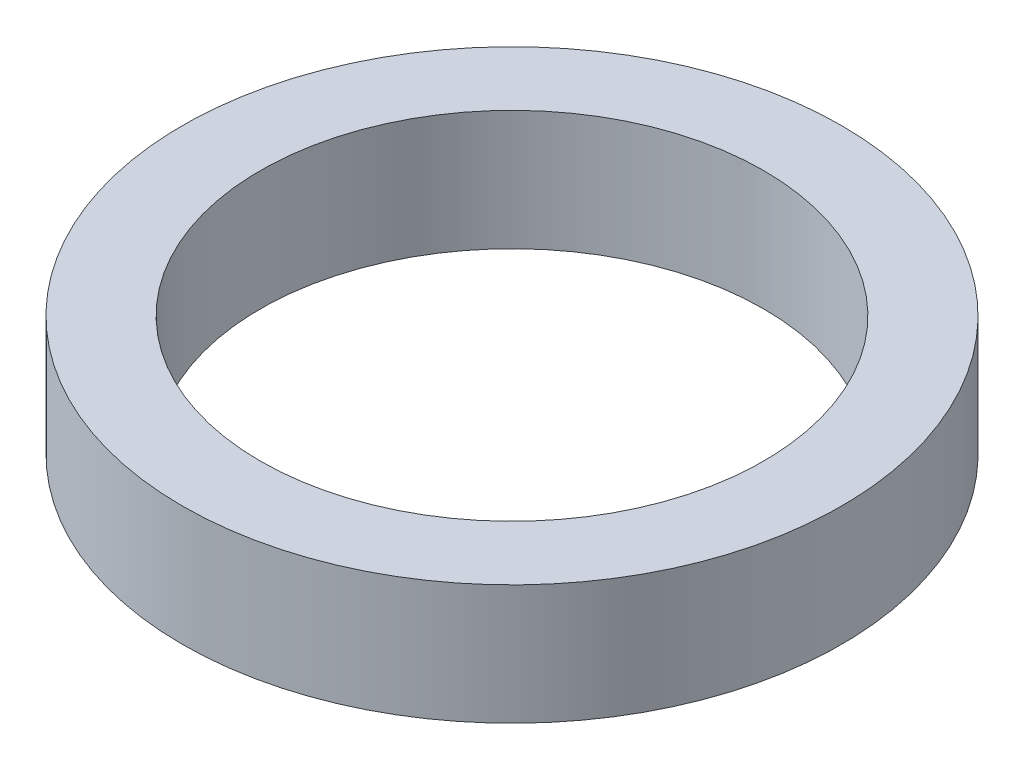
from build123d import *

# Parameters (mm, degrees)
SKETCH1_R           = 5.5
SKETCH1_R_2         = 4.2
BOSS_EXTRUDE1_DEPTH = 2


with BuildPart() as part:
    # Sketch1 → Boss-Extrude1 (new body)
    with BuildSketch(Plane(origin=(0, 0, 0), x_dir=(1, 0, 0), z_dir=(0, 1, 0))):
        with Locations(Location((0, 0, 0), (0, 0, 270))):  # turned: the seam where the file's is
            Circle(SKETCH1_R)
        with Locations(Location((0, 0, 0), (0, 0, 270))):  # turned: the seam where the file's is
            Circle(SKETCH1_R_2, mode=Mode.SUBTRACT)
    extrude(amount=BOSS_EXTRUDE1_DEPTH)


solid = part.part
